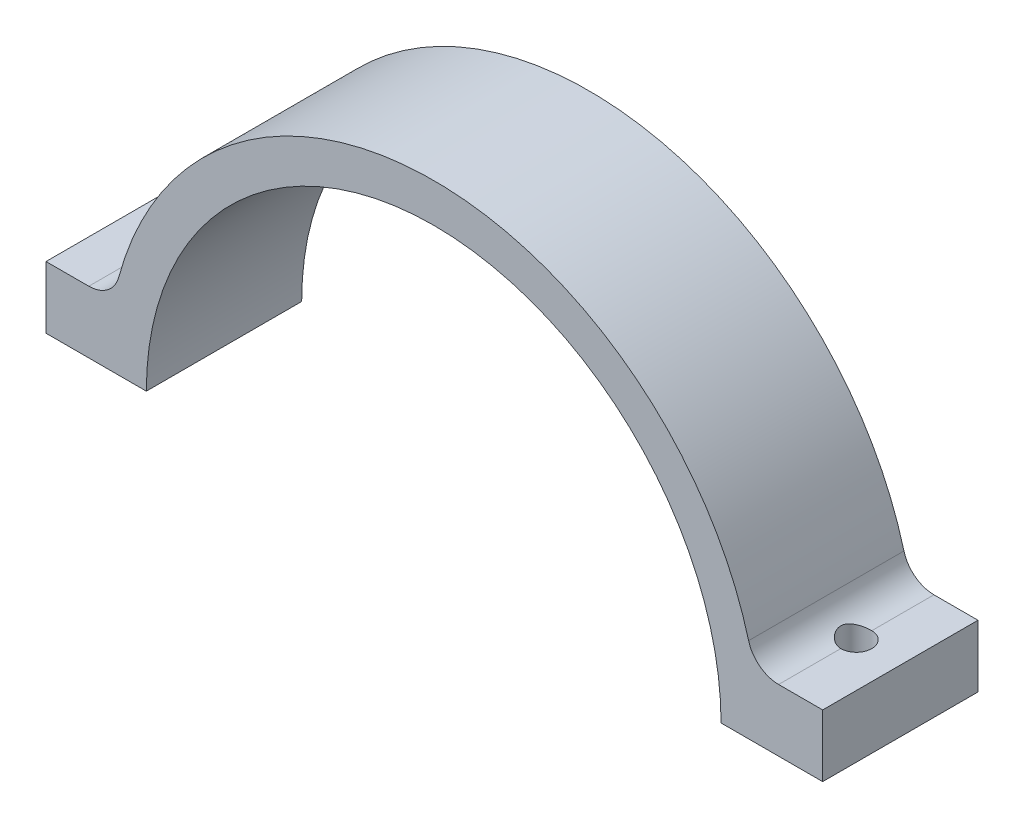
from build123d import *

# Parameters (mm, degrees)
BOSS_EXTRUDE1_DEPTH     = 25.4
SKETCH3_W               = 16.407631331
SKETCH3_H               = 10.16
BOSS_EXTRUDE2_DEPTH     = 25.4
FILLET1_R               = 5.08
SKETCH4_R               = 2.54
CUT_EXTRUDE1_DEPTH      = 44.18
CUT_EXTRUDE1_DEPTH_BACK = 11.16


with BuildPart() as part:
    # Sketch1 → Boss-Extrude1 (new body)
    with BuildSketch(Plane.XY):
        with BuildLine():
            Line((-53.34, 0), (-46.99, 0))
            ThreePointArc((-46.99, 0), (0, 46.99), (46.99, 0))
            Line((46.99, 0), (53.34, 0))
            ThreePointArc((53.34, 0), (0, 53.34), (-53.34, 0))
        make_face()
    extrude(amount=BOSS_EXTRUDE1_DEPTH)

    # Sketch3 → Boss-Extrude2 (add)
    with BuildSketch(Plane(origin=(0, 0, 0), x_dir=(-1, 0, 0), z_dir=(0, 0, -1))):
        with Locations((55.193815666, 5.08)):
            Rectangle(SKETCH3_W, SKETCH3_H)
        with Locations((-55.398553003, 5.08)):
            Rectangle(SKETCH3_W, SKETCH3_H)
    extrude(amount=-BOSS_EXTRUDE2_DEPTH)

    # Fillet1
    fillet1_edges = [part.edges().sort_by_distance(p)[0] for p in [
        (-52.363441445, 10.16, 12.7),
        (52.363441445, 10.16, 12.7),
    ]]
    fillet(fillet1_edges, radius=FILLET1_R)

    # Sketch4 → Cut-Extrude1 (cut, two sides)
    with BuildSketch(Plane(origin=(0, 10.16, 0), x_dir=(1, 0, 0), z_dir=(0, 1, 0))) as cut_extrude1_sk:
        with Locations((-56.39715241, -12.7)):
            Circle(SKETCH4_R)
        with Locations((56.39715241, -12.7)):
            Circle(SKETCH4_R)
    extrude(amount=CUT_EXTRUDE1_DEPTH, mode=Mode.SUBTRACT)
    extrude(cut_extrude1_sk.sketch, amount=-CUT_EXTRUDE1_DEPTH_BACK, mode=Mode.SUBTRACT)


solid = part.part
